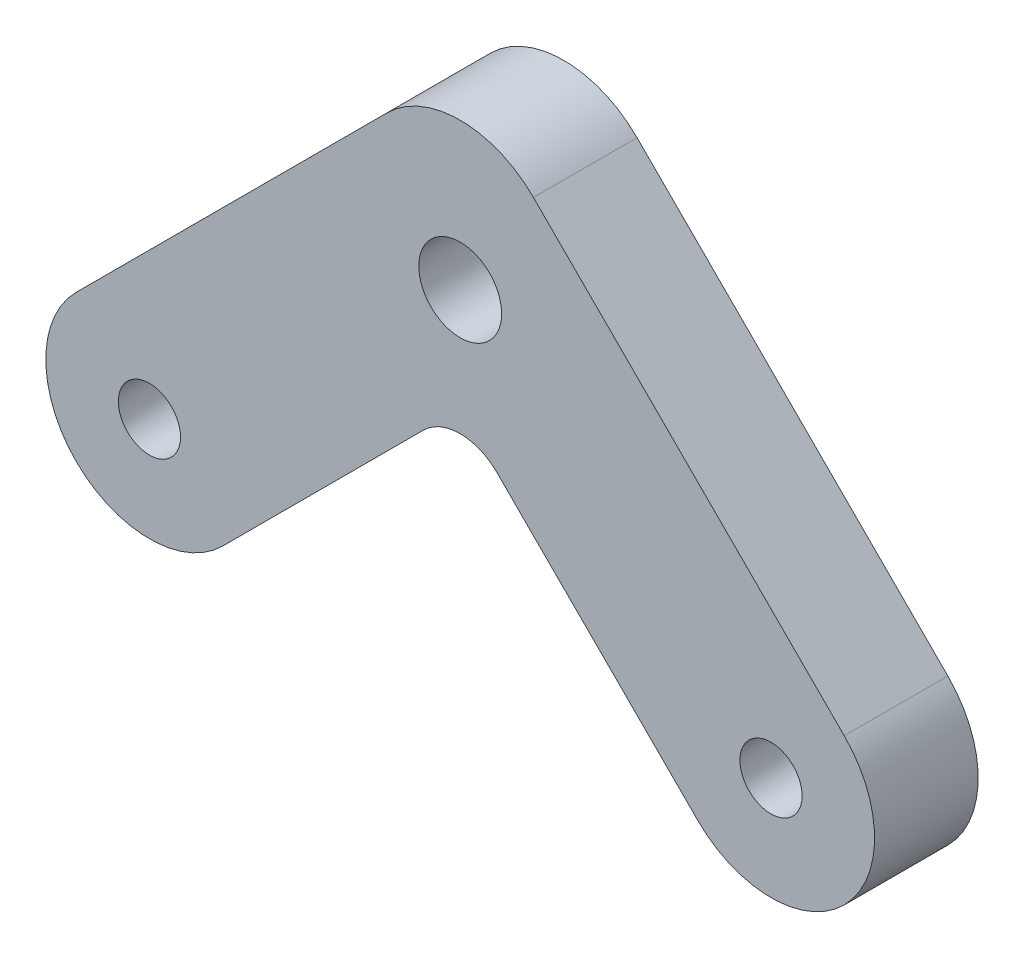
from build123d import *

# Parameters (mm, degrees)
EXTRUDE_1_DEPTH     = 10
SKETCH_2_R          = 4
SKETCH_2_R_2        = 3
CUT_EXTRUDE_1_DEPTH = 10
FILLET_1_R          = 5


with BuildPart() as part:
    # 草图1 → 凸台-拉伸1 (new body)
    with BuildSketch(Plane.XY):
        with BuildLine():
            Line((-7.071067812, 11.264774836), (-37.071067812, -18.735225164))
            ThreePointArc((-37.071067812, -18.735225164), (-37.071067812, -32.877360787), (-22.928932188, -32.877360787))
            Line((-22.928932188, -32.877360787), (0, -9.948428599))
            Line((0, -9.948428599), (22.928932188, -32.877360787))
            ThreePointArc((22.928932188, -32.877360787), (37.071067812, -32.877360787), (37.071067812, -18.735225164))
            Line((37.071067812, -18.735225164), (7.071067812, 11.264774836))
            ThreePointArc((7.071067812, 11.264774836), (0, 14.193707024), (-7.071067812, 11.264774836))
        make_face()
    extrude(amount=EXTRUDE_1_DEPTH)

    # 草图2 → 切除-拉伸1 (cut)
    with BuildSketch(Plane.XY.offset(10)):
        Circle(SKETCH_2_R)
        with Locations((-30, -25.806292976)):
            Circle(SKETCH_2_R_2)
        with Locations((30, -25.806292976)):
            Circle(SKETCH_2_R_2)
    extrude(amount=-CUT_EXTRUDE_1_DEPTH, mode=Mode.SUBTRACT)

    # 圆角1
    fillet_1_edges = [part.edges().sort_by_distance(p)[0] for p in [
        (0, -9.948428599, 5),
    ]]
    fillet(fillet_1_edges, radius=FILLET_1_R)


solid = part.part
